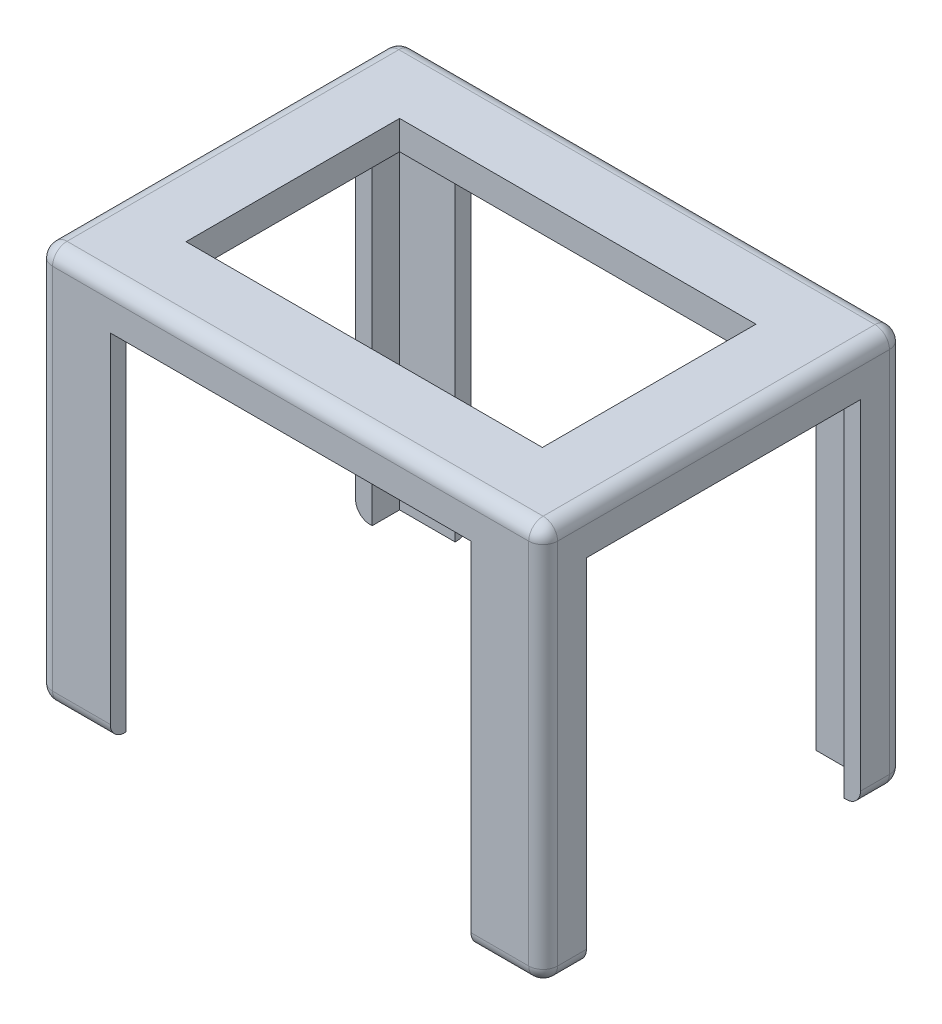
from build123d import *

# Parameters (mm, degrees)
SKETCH1_W               = 88.9
SKETCH1_H               = 63.5
BOSS_EXTRUDE2_DEPTH     = 69.85
FILLET2_R               = 2.54
CUT_EXTRUDE1_START      = -5.08
SKETCH3_W               = 83.058
SKETCH3_H               = 57.912
CUT_EXTRUDE1_DEPTH      = 65.77
SKETCH5_W               = 63.5
SKETCH5_H               = 76.2
CUT_EXTRUDE3_DEPTH      = 1
CUT_EXTRUDE3_DEPTH_BACK = 64.5
SKETCH6_W               = 48.26
SKETCH6_H               = 76.2
CUT_EXTRUDE4_DEPTH      = 1
CUT_EXTRUDE4_DEPTH_BACK = 89.9
SKETCH7_W               = 62.738
SKETCH7_H               = 37.592
CUT_EXTRUDE5_DEPTH      = 6.08


with BuildPart() as part:
    # Sketch1 → Boss-Extrude2 (new body)
    with BuildSketch(Plane(origin=(0, 0, 0), x_dir=(1, 0, 0), z_dir=(0, 1, 0))):
        with Locations((44.45, -31.75)):
            Rectangle(SKETCH1_W, SKETCH1_H)
    extrude(amount=BOSS_EXTRUDE2_DEPTH)

    # Fillet2
    fillet2_edges = [part.edges().sort_by_distance(p)[0] for p in [
        (88.9, 69.85, 31.75),
        (44.45, 69.85, 0),
        (0, 69.85, 31.75),
        (44.45, 0, 0),
        (88.9, 0, 31.75),
        (44.45, 0, 63.5),
        (0, 0, 31.75),
        (0, 34.925, 0),
        (88.9, 34.925, 0),
        (88.9, 34.925, 63.5),
        (0, 34.925, 63.5),
        (44.45, 69.85, 63.5),
    ]]
    fillet(fillet2_edges, radius=FILLET2_R)

    # Sketch3 → Cut-Extrude1 (cut, through all)
    with BuildSketch(Plane(origin=(0, 69.85, 0), x_dir=(1, 0, 0), z_dir=(0, 1, 0)).offset(CUT_EXTRUDE1_START)):
        with Locations((44.45, -31.75)):
            Rectangle(SKETCH3_W, SKETCH3_H)
    extrude(amount=-CUT_EXTRUDE1_DEPTH, mode=Mode.SUBTRACT)

    # Sketch5 → Cut-Extrude3 (cut, two sides)
    with BuildSketch(Plane.XY.offset(63.5)) as cut_extrude3_sk:
        with Locations((44.45, 24.13)):
            Rectangle(SKETCH5_W, SKETCH5_H)
    extrude(amount=CUT_EXTRUDE3_DEPTH, mode=Mode.SUBTRACT)
    extrude(cut_extrude3_sk.sketch, amount=-CUT_EXTRUDE3_DEPTH_BACK, mode=Mode.SUBTRACT)

    # Sketch6 → Cut-Extrude4 (cut, two sides)
    with BuildSketch(Plane.ZY) as cut_extrude4_sk:
        with Locations((31.75, 24.13)):
            Rectangle(SKETCH6_W, SKETCH6_H)
    extrude(amount=CUT_EXTRUDE4_DEPTH, mode=Mode.SUBTRACT)
    extrude(cut_extrude4_sk.sketch, amount=-CUT_EXTRUDE4_DEPTH_BACK, mode=Mode.SUBTRACT)

    # Sketch7 → Cut-Extrude5 (cut, through all)
    with BuildSketch(Plane.XZ.offset(-64.77)):
        with Locations((44.45, 31.75)):
            Rectangle(SKETCH7_W, SKETCH7_H)
    extrude(amount=-CUT_EXTRUDE5_DEPTH, mode=Mode.SUBTRACT)


solid = part.part
